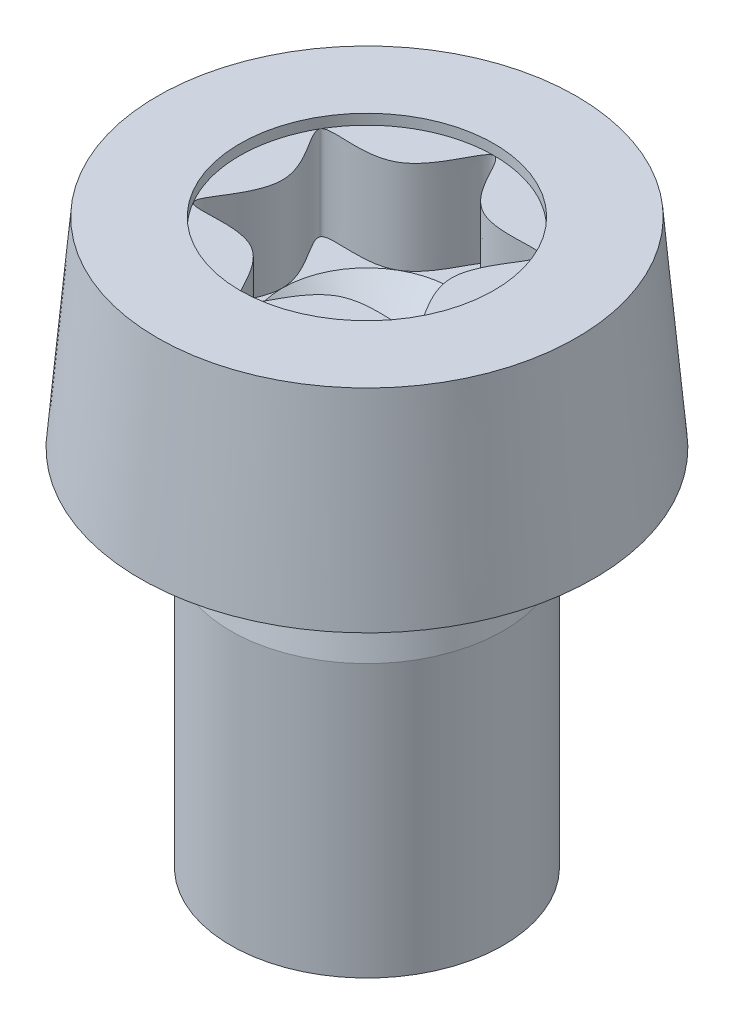
from build123d import *

# Parameters (mm, degrees)
FILLET1_R                 = 0.25
SOCKET_CUT_EXTRUDE1_DEPTH = 2.29
SKETCH3_R                 = 2.8
SOCKET_CUT_EXTRUDE2_DEPTH = 0.229


with BuildPart() as part:
    # Sketch1 → Body-Revolve (revolve)
    with BuildSketch(Plane.XY, mode=Mode.PRIVATE) as body_revolve_sk:
        Polygon((0, 12.4), (4.61504988, 12.4), (5, 8), (3, 8), (2.6, 8), (3, 6), (3, 0), (0, 0), align=None)
    revolve(body_revolve_sk.sketch.rotate(Axis((0, 0, 0), (0, 1, 0)), 90), axis=Axis((0, 0, 0), (0, 1, 0)))

    # Fillet1
    fillet1_edges = [part.edges().sort_by_distance(p)[0] for p in [
        (0, 8, 2.6),
    ]]
    fillet(fillet1_edges, radius=FILLET1_R)

    # Sketch2 → Socket-Cut-Extrude1 (cut)
    with BuildSketch(Plane(origin=(0, 12.4, 0), x_dir=(-1, 0, 0), z_dir=(0, 1, 0))):
        with BuildLine():
            add(Edge.make_bspline(
                [(0, -2.8), (-0.201301877, -2.8), (-0.603905632, -1.045995238), (-3.184377472, -1.838501191), (-1.207811264, 0), (-3.184377472, 1.838501191), (-0.603905632, 1.045995238), (0, 3.677002381), (0.603905632, 1.045995238), (3.184377472, 1.838501191), (1.207811264, 0), (3.184377472, -1.838501191), (0.603905632, -1.045995238), (0.201301877, -2.8), (0, -2.8)],
                knots=[0, 0, 0, 0, 0.083333333, 0.166666667, 0.25, 0.333333333, 0.416666667, 0.5, 0.583333333, 0.666666667, 0.75, 0.833333333, 0.916666667, 1, 1, 1, 1], degree=3))
        make_face()
    extrude(amount=-SOCKET_CUT_EXTRUDE1_DEPTH, mode=Mode.SUBTRACT)

    # Sketch3 → Socket-Cut-Extrude2 (cut)
    with BuildSketch(Plane(origin=(0, 12.4, 0), x_dir=(-1, 0, 0), z_dir=(0, 1, 0))):
        with Locations(Location((0, 0, 0), (0, 0, 90))):
            Circle(SKETCH3_R)
    extrude(amount=-SOCKET_CUT_EXTRUDE2_DEPTH, mode=Mode.SUBTRACT)

    # Sketch4 → Drill-Cut-Revolve (revolve, cut)
    with BuildSketch(Plane.XY, mode=Mode.PRIVATE) as drill_cut_revolve_sk:
        Polygon((0, 10.11), (1.866666667, 10.11), (0, 8.44), align=None)
    revolve(drill_cut_revolve_sk.sketch.rotate(Axis((0, 0, 0), (0, 1, 0)), 270), axis=Axis((0, 0, 0), (0, 1, 0)), mode=Mode.SUBTRACT)


solid = part.part
